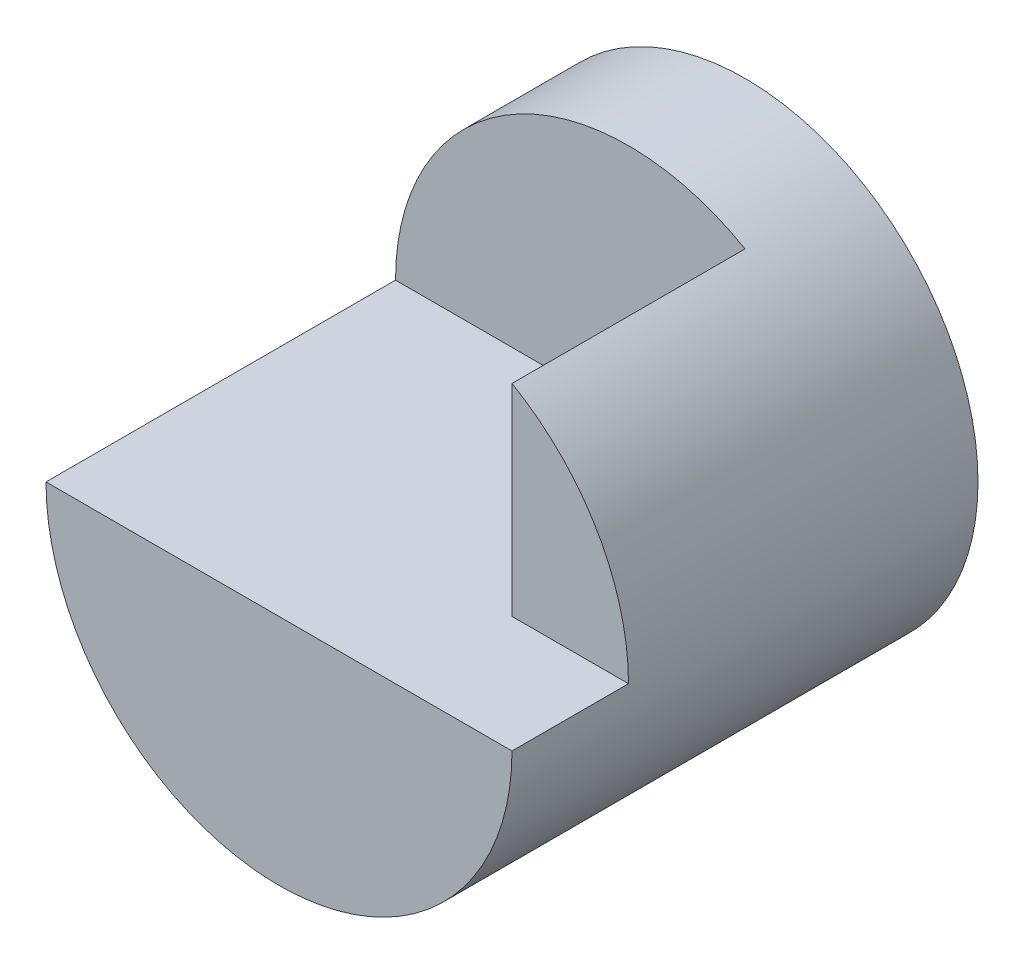
from build123d import *

# Parameters (mm, degrees)
SKETCH1_R               = 20
BOSS_EXTRUDE1_DEPTH     = 40
CUT_EXTRUDE1_DEPTH      = 40
CUT_EXTRUDE1_DEPTH_BACK = 40
SKETCH2_W               = 30
SKETCH2_H               = 2
CUT_EXTRUDE2_DEPTH      = 40
CUT_EXTRUDE2_DEPTH_BACK = 40
SKETCH3_W               = 10
SKETCH3_H               = 20
SKETCH4_W               = 30
SKETCH4_H               = 20
CUT_EXTRUDE4_DEPTH      = 40


with BuildPart() as part:
    # Sketch1 → Boss-Extrude1 (new body)
    with BuildSketch(Plane.XY):
        Circle(SKETCH1_R)
    extrude(amount=BOSS_EXTRUDE1_DEPTH)

    # Sketch2 → Cut-Extrude1 (cut, two sides: drawn at the far end of the back side and taken through both)
    with BuildSketch(Plane(origin=(0, 0, 0), x_dir=(0, 0, -1), z_dir=(1, 0, 0)).offset(-CUT_EXTRUDE1_DEPTH_BACK)):
        with Locations((-25, 19)):
            Rectangle(SKETCH2_W, SKETCH2_H)
    extrude(amount=CUT_EXTRUDE1_DEPTH + CUT_EXTRUDE1_DEPTH_BACK, mode=Mode.SUBTRACT)

    # Sketch3 → Cut-Extrude2 (cut, two sides: drawn at the far end of the back side and taken through both)
    with BuildSketch(Plane(origin=(0, 0, 0), x_dir=(0, 0, -1), z_dir=(1, 0, 0)).offset(-CUT_EXTRUDE2_DEPTH_BACK)):
        with Locations((-35, 10)):
            Rectangle(SKETCH3_W, SKETCH3_H)
    extrude(amount=CUT_EXTRUDE2_DEPTH + CUT_EXTRUDE2_DEPTH_BACK, mode=Mode.SUBTRACT)

    # Sketch4 → Cut-Extrude4 (cut)
    with BuildSketch(Plane(origin=(0, 0, 0), x_dir=(1, 0, 0), z_dir=(0, 1, 0))):
        with Locations((-5, -20)):
            Rectangle(SKETCH4_W, SKETCH4_H)
    extrude(amount=CUT_EXTRUDE4_DEPTH, mode=Mode.SUBTRACT)


solid = part.part
